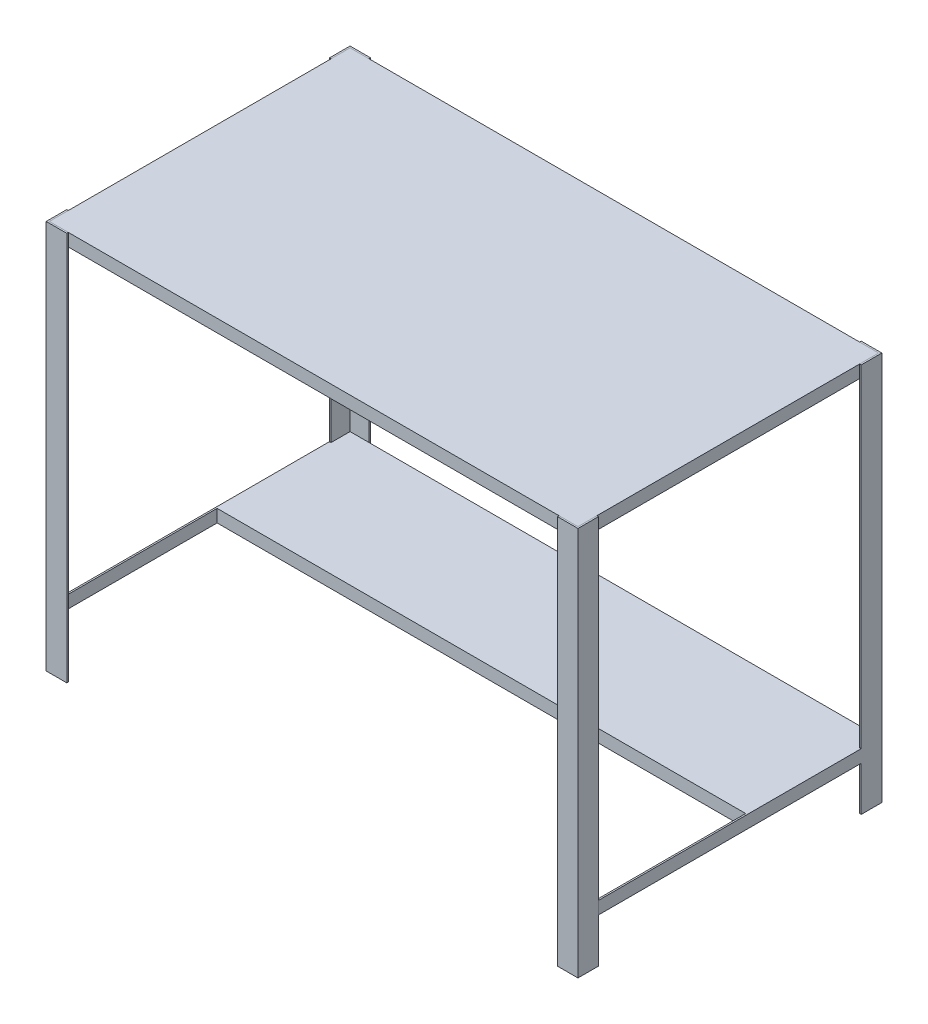
from build123d import *

# Parameters (mm, degrees)
SKETCH1_W                  = 1060.45
SKETCH1_H                  = 603.25
BOSS_EXTRUDE1_DEPTH        = 25.4
BOSS_EXTRUDE2_DEPTH        = 755.65
BOSS_EXTRUDE2_DEPTH_BACK   = 25.4
BOSS_EXTRUDE2_2_DEPTH      = 755.65
BOSS_EXTRUDE2_2_DEPTH_BACK = 25.4
BOSS_EXTRUDE2_3_DEPTH      = 755.65
BOSS_EXTRUDE2_3_DEPTH_BACK = 25.4
BOSS_EXTRUDE2_4_DEPTH      = 755.65
BOSS_EXTRUDE2_4_DEPTH_BACK = 25.4
SKETCH3_W                  = 266.7
SKETCH3_H                  = 25.4
BOSS_EXTRUDE3_DEPTH        = 1060.45
SKETCH4_W                  = 3.175
SKETCH4_H                  = 25.4
BOSS_EXTRUDE4_DEPTH        = 527.05


with BuildPart() as part:
    # Sketch1 → Boss-Extrude1 (new body)
    with BuildSketch(Plane(origin=(0, 0, 0), x_dir=(1, 0, 0), z_dir=(0, 1, 0))):
        Rectangle(SKETCH1_W, SKETCH1_H)
    extrude(amount=BOSS_EXTRUDE1_DEPTH)


with BuildPart() as body_2:
    # Sketch2 → Boss-Extrude2 (new body, two sides)
    with BuildSketch(Plane(origin=(0, 0, 0), x_dir=(-1, 0, 0), z_dir=(0, -1, 0))) as boss_extrude2_sk:
        Polygon((492.125, -301.625), (492.125, -304.8), (533.4, -304.8), (533.4, -263.525), (530.225, -263.525), (530.225, -301.625), align=None)
    extrude(amount=BOSS_EXTRUDE2_DEPTH)
    extrude(boss_extrude2_sk.sketch, amount=-BOSS_EXTRUDE2_DEPTH_BACK)



with BuildPart() as body_3:
    # Sketch2 → Boss-Extrude2 2 (new body, two sides)
    with BuildSketch(Plane(origin=(0, 0, 0), x_dir=(-1, 0, 0), z_dir=(0, -1, 0))) as boss_extrude2_2_sk:
        Polygon((-530.225, -301.625), (-492.125, -301.625), (-492.125, -304.8), (-533.4, -304.8), (-533.4, -263.525), (-530.225, -263.525), align=None)
    extrude(amount=BOSS_EXTRUDE2_2_DEPTH)
    extrude(boss_extrude2_2_sk.sketch, amount=-BOSS_EXTRUDE2_2_DEPTH_BACK)


with BuildPart() as body_4:
    # Sketch2 → Boss-Extrude2 3 (new body, two sides)
    with BuildSketch(Plane(origin=(0, 0, 0), x_dir=(-1, 0, 0), z_dir=(0, -1, 0))) as boss_extrude2_3_sk:
        Polygon((-492.125, 301.625), (-492.125, 304.8), (-533.4, 304.8), (-533.4, 263.525), (-530.225, 263.525), (-530.225, 301.625), align=None)
    extrude(amount=BOSS_EXTRUDE2_3_DEPTH)
    extrude(boss_extrude2_3_sk.sketch, amount=-BOSS_EXTRUDE2_3_DEPTH_BACK)

    # Sketch3 → Boss-Extrude3 (add)
    with BuildSketch(Plane.ZY.offset(-530.225)):
        with Locations((-168.275, -654.05)):
            Rectangle(SKETCH3_W, SKETCH3_H)
    extrude(amount=BOSS_EXTRUDE3_DEPTH)


with BuildPart() as body_5:
    # Sketch2 → Boss-Extrude2 4 (new body, two sides)
    with BuildSketch(Plane(origin=(0, 0, 0), x_dir=(-1, 0, 0), z_dir=(0, -1, 0))) as boss_extrude2_4_sk:
        Polygon((530.225, 301.625), (492.125, 301.625), (492.125, 304.8), (533.4, 304.8), (533.4, 263.525), (530.225, 263.525), align=None)
    extrude(amount=BOSS_EXTRUDE2_4_DEPTH)
    extrude(boss_extrude2_4_sk.sketch, amount=-BOSS_EXTRUDE2_4_DEPTH_BACK)


with BuildPart() as body_2_1:
    add(body_2.part)

    add(body_4.part)  # Boss-Extrude4 merges body 4

    add(body_5.part)  # Boss-Extrude4 merges body 5
    # Sketch4 → Boss-Extrude4 (add)
    with BuildSketch(Plane(origin=(0, 0, -263.525), x_dir=(-1, 0, 0), z_dir=(0, 0, -1))):
        with Locations((531.8125, -654.05)):
            Rectangle(SKETCH4_W, SKETCH4_H)
    boss_extrude4 = extrude(amount=-BOSS_EXTRUDE4_DEPTH)

    # Mirror2: Boss-Extrude4 across plane
    add(boss_extrude4.mirror(Plane(origin=(0, 0, 0), x_dir=(0, 0, 1), z_dir=(1, 0, 0))))


solid = Compound([part.part, body_3.part, body_2_1.part])
